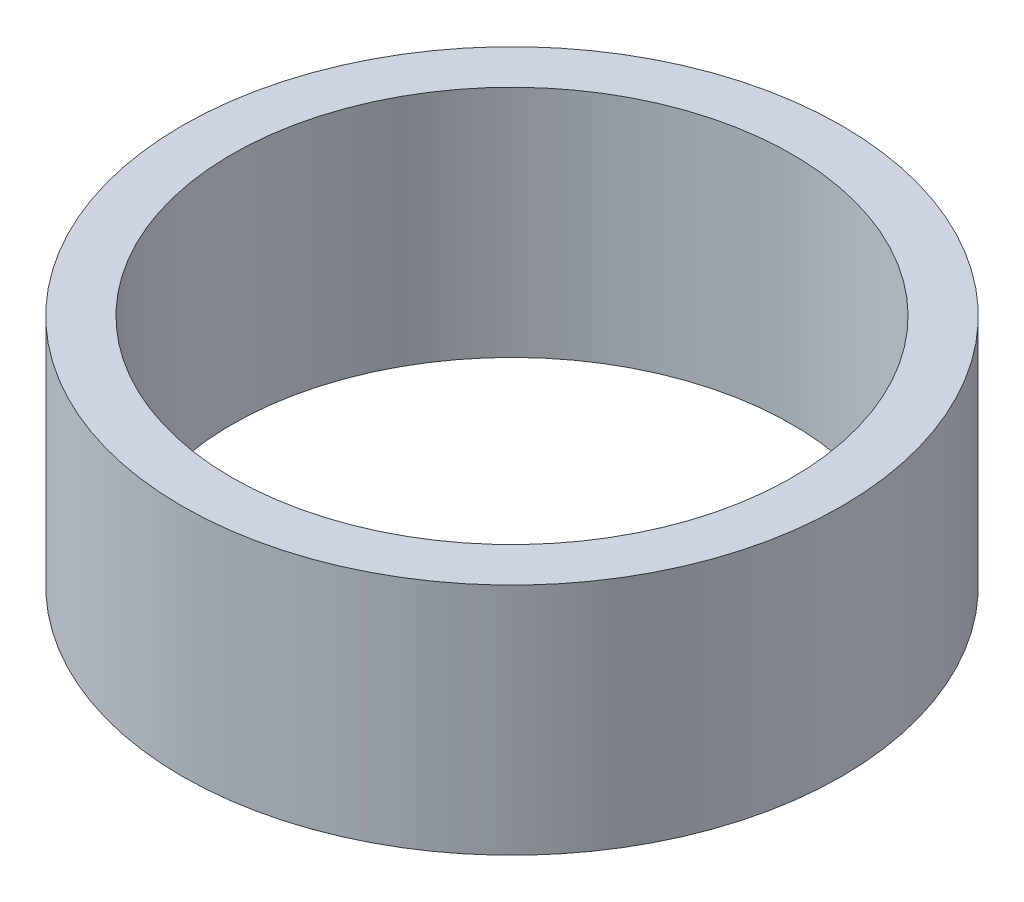
from build123d import *

# Parameters (mm, degrees)
SKETCH1_R           = 23.25
BOSS_EXTRUDE1_DEPTH = 16.5
SKETCH2_R           = 19.75
CUT_EXTRUDE1_DEPTH  = 16.5


with BuildPart() as part:
    # Sketch1 → Boss-Extrude1 (new body)
    with BuildSketch(Plane(origin=(0, 0, 0), x_dir=(1, 0, 0), z_dir=(0, 1, 0))):
        Circle(SKETCH1_R)
    extrude(amount=BOSS_EXTRUDE1_DEPTH)

    # Sketch2 → Cut-Extrude1 (cut)
    with BuildSketch(Plane(origin=(0, 16.5, 0), x_dir=(1, 0, 0), z_dir=(0, 1, 0))):
        Circle(SKETCH2_R)
    extrude(amount=-CUT_EXTRUDE1_DEPTH, mode=Mode.SUBTRACT)


solid = part.part
